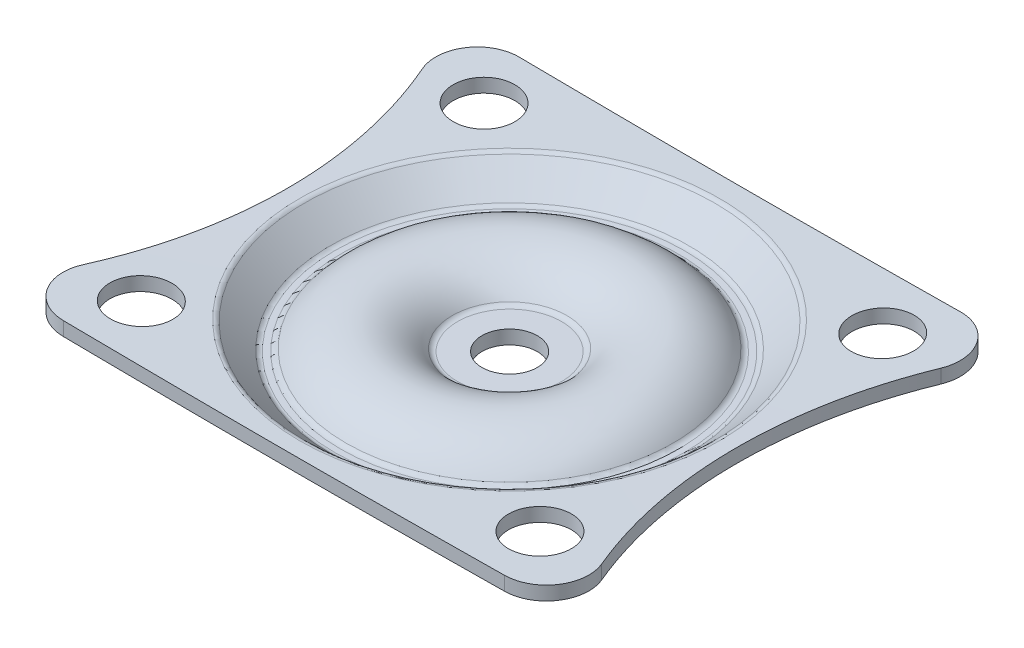
from build123d import *

# Parameters (mm, degrees)
CROQUIS2_W            = 83.65519823
CROQUIS2_H            = 71.804045148
CORTAR_EXTRUIR4_DEPTH = 10
CROQUIS2_6_R          = 2.25
CROQUIS2_6_R_2        = 2.25298443
CORTAR_EXTRUIR5_DEPTH = 10
CROQUIS3_R            = 2
CORTAR_EXTRUIR6_DEPTH = 10


with BuildPart() as part:
    # Croquis1 → Revolución1 (revolve)
    with BuildSketch(Plane.XY):
        with BuildLine():
            Line((3.763832281, 0), (0, 0))
            Line((0, 0), (0, -1))
            Line((0, -1), (3.763832281, -1))
            ThreePointArc((3.763832281, -1), (4.40491472, -0.856102248), (4.92299673, -0.452017741))
            ThreePointArc((4.92299673, -0.452017741), (7.994496433, 1), (11.065996136, -0.452017741))
            ThreePointArc((11.065996136, -0.452017741), (11.584078146, -0.856102248), (12.225160585, -1))
            Line((12.225160585, -1), (12.65047403, -1))
            ThreePointArc((12.65047403, -1), (13.198865955, -0.896161272), (13.67133212, -0.599021729))
            Line((13.67133212, -0.599021729), (15.258817463, 0.875559903))
            ThreePointArc((15.258817463, 0.875559903), (15.412659567, 0.973157537), (15.591255973, 1.00915774))
            Line((15.591255973, 1.00915774), (30.541484826, 1.243831091))
            Line((30.541484826, 1.243831091), (30.525789785, 2.243707916))
            Line((30.525789785, 2.243707916), (15.191853644, 2.003011522))
            ThreePointArc((15.191853644, 2.003011522), (15.013257238, 1.967011319), (14.859415134, 1.869413685))
            Line((14.859415134, 1.869413685), (12.99076006, 0.133659424))
            ThreePointArc((12.99076006, 0.133659424), (12.833271339, 0.034612909), (12.65047403, 0))
            Line((12.65047403, 0), (12.225160585, 0))
            ThreePointArc((12.225160585, 0), (12.011466439, 0.047965917), (11.838772435, 0.182660753))
            ThreePointArc((11.838772435, 0.182660753), (7.994496433, 2), (4.15022043, 0.182660753))
            ThreePointArc((4.15022043, 0.182660753), (3.977526427, 0.047965917), (3.763832281, 0))
        make_face()
    revolve(axis=Axis((0, -1, 0), (0, -1, 0)))

    # Croquis2 → Cortar-Extruir4 (cut)
    with BuildSketch(Plane(origin=(0, 0, 0), x_dir=(1, 0, 0), z_dir=(0, 1, 0))):
        with Locations((0, 0.174281663)):
            Rectangle(CROQUIS2_W, CROQUIS2_H)
        with BuildLine():
            Line((15.96021258, -16.325718337), (-15.96021258, -16.325718337))
            ThreePointArc((-15.96021258, -16.325718337), (-18.496422252, -14.961624224), (-18.756401251, -12.093606936))
            ThreePointArc((-18.756401251, -12.093606936), (-16.25, 0.174281663), (-18.756401251, 12.442170262))
            ThreePointArc((-18.756401251, 12.442170262), (-18.496422252, 15.31018755), (-15.96021258, 16.674281663))
            Line((-15.96021258, 16.674281663), (15.96021258, 16.674281663))
            ThreePointArc((15.96021258, 16.674281663), (18.496422252, 15.31018755), (18.756401251, 12.442170262))
            ThreePointArc((18.756401251, 12.442170262), (16.25, 0.174281663), (18.756401251, -12.093606936))
            ThreePointArc((18.756401251, -12.093606936), (18.496422252, -14.961624224), (15.96021258, -16.325718337))
        make_face(mode=Mode.SUBTRACT)
    extrude(amount=CORTAR_EXTRUIR4_DEPTH, mode=Mode.SUBTRACT)

    # Croquis2_6 → Cortar-Extruir5 (cut)
    with BuildSketch(Plane(origin=(0, 0, 0), x_dir=(1, 0, 0), z_dir=(0, 1, 0))):
        with Locations((-14.422555001, 12.574281663)):
            Circle(CROQUIS2_6_R)
        with Locations((-14.422555001, -12.225718337)):
            Circle(CROQUIS2_6_R_2)
        with Locations((14.422555001, -12.225718337)):
            Circle(CROQUIS2_6_R_2)
        with Locations((14.422555001, 12.574281663)):
            Circle(CROQUIS2_6_R)
    extrude(amount=CORTAR_EXTRUIR5_DEPTH, mode=Mode.SUBTRACT)

    # Croquis3 → Cortar-Extruir6 (cut)
    with BuildSketch(Plane(origin=(0, 0, 0), x_dir=(1, 0, 0), z_dir=(0, 1, 0))):
        Circle(CROQUIS3_R)
    extrude(amount=-CORTAR_EXTRUIR6_DEPTH, mode=Mode.SUBTRACT)


solid = part.part
